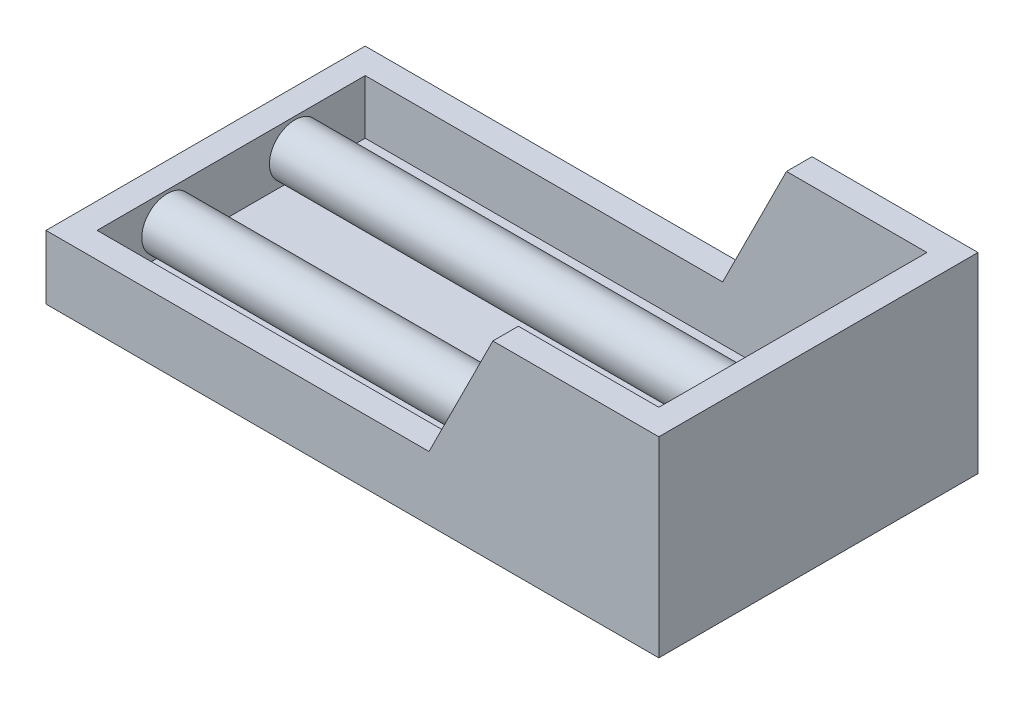
from build123d import *

# Parameters (mm, degrees)
SKETCH1_W             = 48
SKETCH1_H             = 25
BOSS_EXTRUDE1_DEPTH   = 15
CUT_EXTRUDE1_DEPTH    = 26
SKETCH4_W             = 44
SKETCH4_H             = 21
CUT_EXTRUDE2_DEPTH    = 15.25
SKETCH5_R             = 2
BOSS_EXTRUDE4_DEPTH   = 44
BOSS_EXTRUDE4_2_DEPTH = 44
FILLET1_R             = 1
FILLET3_R             = 1


with BuildPart() as part:
    # Sketch1 → Boss-Extrude1 (new body)
    with BuildSketch(Plane(origin=(0, 0, 0), x_dir=(1, 0, 0), z_dir=(0, 1, 0))):
        with Locations((14, 7.5)):
            Rectangle(SKETCH1_W, SKETCH1_H)
    extrude(amount=BOSS_EXTRUDE1_DEPTH)

    # Sketch2 → Cut-Extrude1 (cut, through all)
    with BuildSketch(Plane.XY.offset(5)):
        Polygon((25, 15), (20, 5), (-10, 5), (-10, 15), align=None)
    extrude(amount=-CUT_EXTRUDE1_DEPTH, mode=Mode.SUBTRACT)

    # Sketch4 → Cut-Extrude2 (cut, through all)
    with BuildSketch(Plane(origin=(0, 0.75, 0), x_dir=(1, 0, 0), z_dir=(0, 1, 0))):
        with Locations((14, 7.5)):
            Rectangle(SKETCH4_W, SKETCH4_H)
    extrude(amount=CUT_EXTRUDE2_DEPTH, mode=Mode.SUBTRACT)


with BuildPart() as body_2:
    # Sketch5 → Boss-Extrude4 (new body)
    with BuildSketch(Plane(origin=(-8, 0, 0), x_dir=(0, 0, -1), z_dir=(1, 0, 0))):
        with Locations((12.5, 2.75)):
            Circle(SKETCH5_R)
    extrude(amount=BOSS_EXTRUDE4_DEPTH)

    # Fillet1
    fillet1_edges = [body_2.edges().sort_by_distance(p)[0] for p in [
        (36, 2.75, -10.5),
    ]]
    fillet(fillet1_edges, radius=FILLET1_R)


with BuildPart() as body_3:
    # Sketch5 → Boss-Extrude4 2 (new body)
    with BuildSketch(Plane(origin=(-8, 0, 0), x_dir=(0, 0, -1), z_dir=(1, 0, 0))):
        with Locations((2.5, 2.75)):
            Circle(SKETCH5_R)
    extrude(amount=BOSS_EXTRUDE4_2_DEPTH)

    # Fillet3
    fillet3_edges = [body_3.edges().sort_by_distance(p)[0] for p in [
        (36, 2.75, -0.5),
    ]]
    fillet(fillet3_edges, radius=FILLET3_R)


solid = Compound([part.part, body_2.part, body_3.part])
